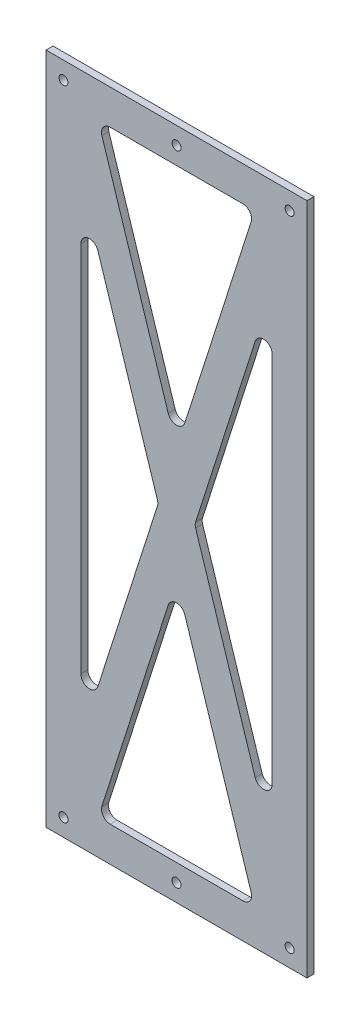
from build123d import *

# Parameters (mm, degrees)
SKETCH2_W           = 150
SKETCH2_H           = 387
SKETCH2_R           = 2.6
BOSS_EXTRUDE1_DEPTH = 4
CUT_EXTRUDE1_DEPTH  = 10


with BuildPart() as part:
    # Sketch2 → Boss-Extrude1 (new body)
    with BuildSketch(Plane.XY.offset(30)):
        with Locations((-125, -183.5)):
            Rectangle(SKETCH2_W, SKETCH2_H)
        with Locations((-190, 0)):
            Circle(SKETCH2_R, mode=Mode.SUBTRACT)
        with Locations((-60, 0)):
            Circle(SKETCH2_R, mode=Mode.SUBTRACT)
        with Locations((-125, 0)):
            Circle(SKETCH2_R, mode=Mode.SUBTRACT)
        with Locations((-60, -367)):
            Circle(SKETCH2_R, mode=Mode.SUBTRACT)
        with Locations((-125, -367)):
            Circle(SKETCH2_R, mode=Mode.SUBTRACT)
        with Locations((-190, -367)):
            Circle(SKETCH2_R, mode=Mode.SUBTRACT)
    extrude(amount=BOSS_EXTRUDE1_DEPTH)

    # Sketch3 → Cut-Extrude1 (cut)
    with BuildSketch(Plane.XY.offset(34)):
        with BuildLine():
            Line((-163.151021772, -10), (-86.848978228, -10))
            ThreePointArc((-86.848978228, -10), (-82.810612321, -12.051847901), (-82.086691458, -16.523359681))
            Line((-82.086691458, -16.523359681), (-120.23771323, -135.790075557))
            ThreePointArc((-120.23771323, -135.790075557), (-125, -139.266715876), (-129.76228677, -135.790075557))
            Line((-129.76228677, -135.790075557), (-167.913308542, -16.523359681))
            ThreePointArc((-167.913308542, -16.523359681), (-167.189387679, -12.051847901), (-163.151021772, -10))
        make_face()
        with BuildLine():
            Line((-180, -76.424605697), (-180, -290.575394303))
            ThreePointArc((-180, -290.575394303), (-175.770897577, -295.515608562), (-170.23771323, -292.098753984))
            Line((-170.23771323, -292.098753984), (-135.986449838, -185.023359681))
            ThreePointArc((-135.986449838, -185.023359681), (-135.748736609, -183.5), (-135.986449838, -181.976640319))
            Line((-135.986449838, -181.976640319), (-170.23771323, -74.901246016))
            ThreePointArc((-170.23771323, -74.901246016), (-175.770897577, -71.484391438), (-180, -76.424605697))
        make_face()
        with BuildLine():
            Line((-163.151021772, -357), (-86.848978228, -357))
            ThreePointArc((-86.848978228, -357), (-82.810612321, -354.948152099), (-82.086691458, -350.476640319))
            Line((-82.086691458, -350.476640319), (-120.23771323, -231.209924443))
            ThreePointArc((-120.23771323, -231.209924443), (-125, -227.733284124), (-129.76228677, -231.209924443))
            Line((-129.76228677, -231.209924443), (-167.913308542, -350.476640319))
            ThreePointArc((-167.913308542, -350.476640319), (-167.189387679, -354.948152099), (-163.151021772, -357))
        make_face()
        with BuildLine():
            Line((-70, -76.424605697), (-70, -290.575394303))
            ThreePointArc((-70, -290.575394303), (-74.229102423, -295.515608562), (-79.76228677, -292.098753984))
            Line((-79.76228677, -292.098753984), (-114.013550162, -185.023359681))
            ThreePointArc((-114.013550162, -185.023359681), (-114.251263391, -183.5), (-114.013550162, -181.976640319))
            Line((-114.013550162, -181.976640319), (-79.76228677, -74.901246016))
            ThreePointArc((-79.76228677, -74.901246016), (-74.229102423, -71.484391438), (-70, -76.424605697))
        make_face()
    extrude(amount=-CUT_EXTRUDE1_DEPTH, mode=Mode.SUBTRACT)


solid = part.part
